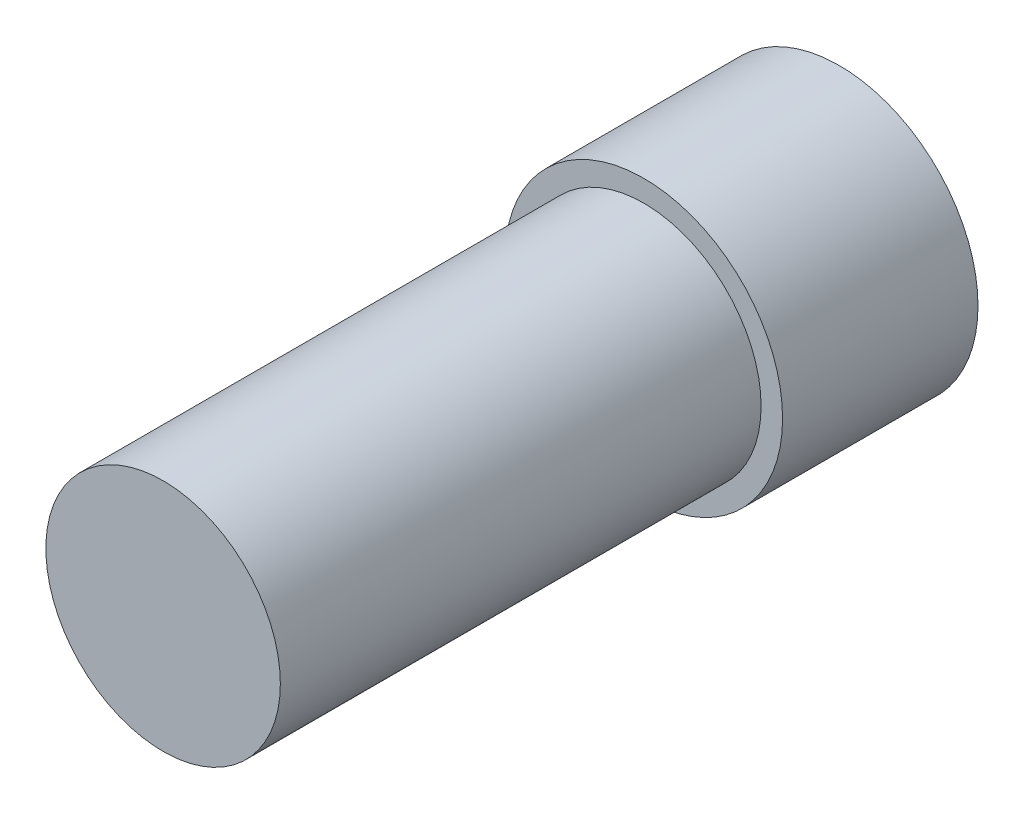
from build123d import *

# Parameters (mm, degrees)
SKETCH1_R           = 7.1
SKETCH1_R_2         = 3
BOSS_EXTRUDE1_DEPTH = 10
SKETCH2_R           = 6
BOSS_EXTRUDE2_DEPTH = 24.6


with BuildPart() as part:
    # Sketch1 → Boss-Extrude1 (new body)
    with BuildSketch(Plane.XY):
        Circle(SKETCH1_R)
        Circle(SKETCH1_R_2, mode=Mode.SUBTRACT)
    extrude(amount=BOSS_EXTRUDE1_DEPTH)

    # Sketch2 → Boss-Extrude2 (add)
    with BuildSketch(Plane.XY.offset(10)):
        Circle(SKETCH2_R)
    extrude(amount=BOSS_EXTRUDE2_DEPTH)


solid = part.part
